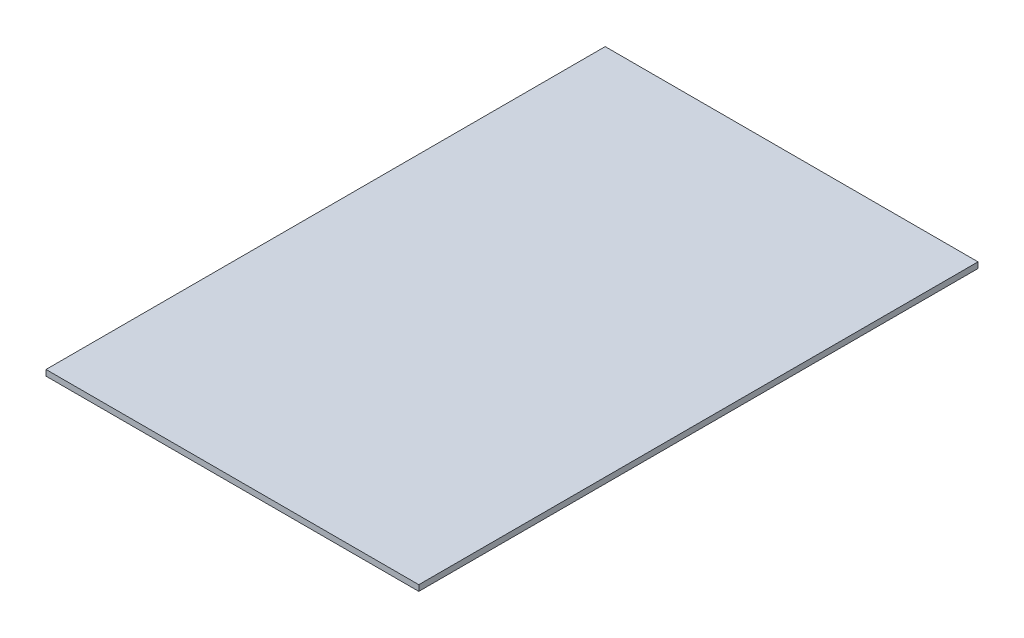
from build123d import *

# Parameters (mm, degrees)
SKETCH1_W           = 1219.2
SKETCH1_H           = 1828.8
BOSS_EXTRUDE1_DEPTH = 19.05


with BuildPart() as part:
    # Sketch1 → Boss-Extrude1 (new body)
    with BuildSketch(Plane(origin=(0, 0, 0), x_dir=(1, 0, 0), z_dir=(0, 1, 0))):
        Rectangle(SKETCH1_W, SKETCH1_H)
    extrude(amount=-BOSS_EXTRUDE1_DEPTH)


solid = part.part
